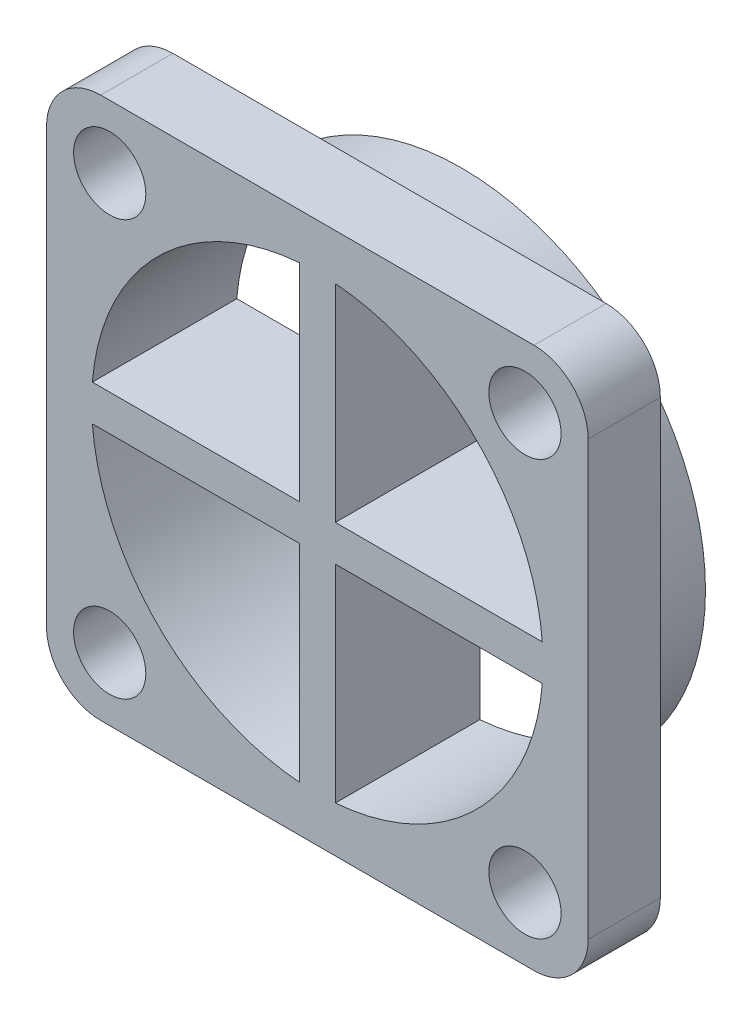
from build123d import *

# Parameters (mm, degrees)
SKETCH1_R               = 13.5
BOSS_EXTRUDE1_DEPTH     = 4
SKETCH2_W               = 30
SKETCH2_H               = 30
BOSS_EXTRUDE2_DEPTH     = 4
FILLET1_R               = 3
CUT_EXTRUDE1_START      = -9
CUT_EXTRUDE1_DEPTH      = 17
MIRROR2_START           = -9
MIRROR2_COPY_1_DEPTH    = 17
SKETCH5_R               = 2
CUT_EXTRUDE2_DEPTH      = 8
MIRROR4_COPY_1_SKETCH_R = 2
MIRROR4_COPY_1_DEPTH    = 8


with BuildPart() as part:
    # Sketch1 → Boss-Extrude1 (new body)
    with BuildSketch(Plane.XY):
        Circle(SKETCH1_R)
    extrude(amount=BOSS_EXTRUDE1_DEPTH)

    # Sketch2 → Boss-Extrude2 (add)
    with BuildSketch(Plane.XY.offset(4)):
        Rectangle(SKETCH2_W, SKETCH2_H)
    extrude(amount=BOSS_EXTRUDE2_DEPTH)

    # Fillet1
    fillet1_edges = [part.edges().sort_by_distance(p)[0] for p in [
        (15, -15, 6),
        (15, 15, 6),
        (-15, 15, 6),
        (-15, -15, 6),
    ]]
    fillet(fillet1_edges, radius=FILLET1_R)

    # Sketch4 → Cut-Extrude1 (cut)
    with BuildSketch(Plane(origin=(0, 0, 0), x_dir=(-1, 0, 0), z_dir=(0, 0, -1)).offset(CUT_EXTRUDE1_START)):
        with BuildLine():
            Line((-12.459935794, 1), (-1, 1))
            Line((-1, 1), (-1, 12.459935794))
            ThreePointArc((-1, 12.459935794), (-8.838834765, 8.838834765), (-12.459935794, 1))
        make_face()
    cut_extrude1 = extrude(amount=CUT_EXTRUDE1_DEPTH, mode=Mode.SUBTRACT)

    # Mirror1: Cut-Extrude1 across plane
    add(cut_extrude1.mirror(Plane(origin=(0, 0, 0), x_dir=(0, 0, 1), z_dir=(1, 0, 0))), mode=Mode.SUBTRACT)

    # Mirror2: Cut-Extrude1 across plane
    add(cut_extrude1.mirror(Plane.ZX), mode=Mode.SUBTRACT)

    # Mirror2 copy 1 sketch → Mirror2 copy 1 (cut)
    with BuildSketch(Plane(origin=(0, 0, 0), x_dir=(1, 0, 0), z_dir=(0, 0, -1)).offset(MIRROR2_START)):
        with BuildLine():
            Line((-12.459935794, 1), (-1, 1))
            Line((-1, 1), (-1, 12.459935794))
            ThreePointArc((-1, 12.459935794), (-8.838834765, 8.838834765), (-12.459935794, 1))
        make_face()
    extrude(amount=MIRROR2_COPY_1_DEPTH, mode=Mode.SUBTRACT)

    # Sketch5 → Cut-Extrude2 (cut)
    with BuildSketch(Plane(origin=(0, 0, 4), x_dir=(-1, 0, 0), z_dir=(0, 0, -1))):
        with Locations((-11.5, 11.5)):
            Circle(SKETCH5_R)
    cut_extrude2 = extrude(amount=-CUT_EXTRUDE2_DEPTH, mode=Mode.SUBTRACT)

    # Mirror3: Cut-Extrude2 across plane
    add(cut_extrude2.mirror(Plane.ZX), mode=Mode.SUBTRACT)

    # Mirror4: Cut-Extrude2 across plane
    add(cut_extrude2.mirror(Plane(origin=(0, 0, 0), x_dir=(0, 0, 1), z_dir=(1, 0, 0))), mode=Mode.SUBTRACT)

    # Mirror4 copy 1 sketch → Mirror4 copy 1 (cut)
    with BuildSketch(Plane(origin=(0, 0, 4), x_dir=(1, 0, 0), z_dir=(0, 0, -1))):
        with Locations((-11.5, 11.5)):
            Circle(MIRROR4_COPY_1_SKETCH_R)
    extrude(amount=-MIRROR4_COPY_1_DEPTH, mode=Mode.SUBTRACT)


solid = part.part
